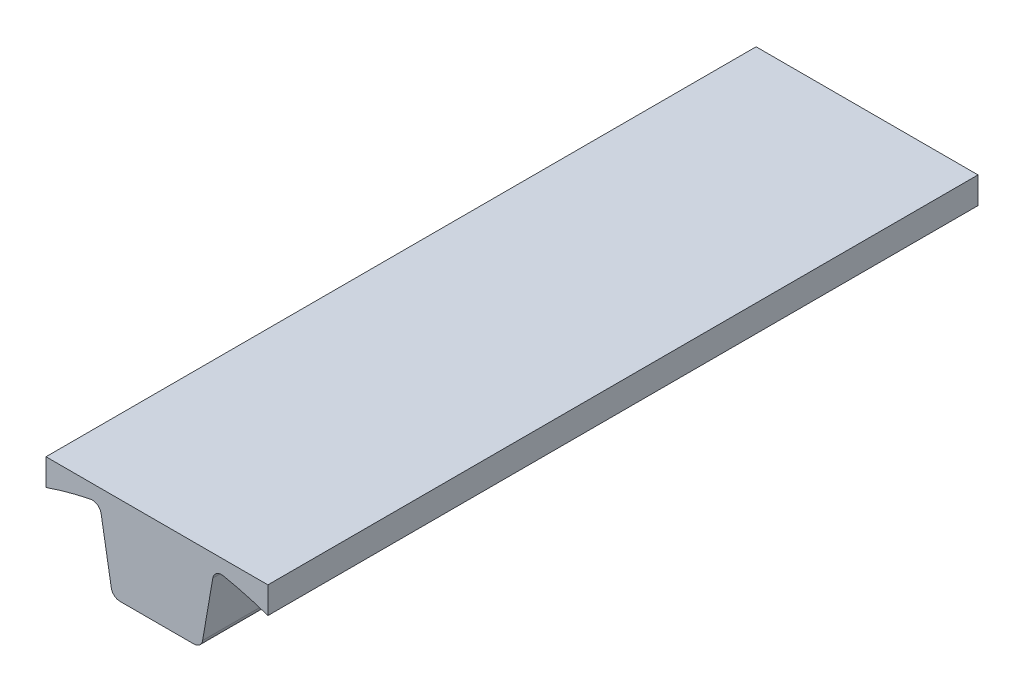
from build123d import *

# Parameters (mm, degrees)
BOSS_EXTRUDE1_DEPTH = 203.2
FILLET1_R           = 2.54
FILLET2_R           = 2.54
FILLET3_R           = 2.54
SKETCH2_R           = 2.667
CUT_EXTRUDE1_DEPTH  = 11.43


with BuildPart() as part:
    # Sketch1 → Boss-Extrude1 (new body)
    with BuildSketch(Plane.XY):
        with BuildLine():
            Line((-12.7, 73.846320133), (12.7, 73.846320133))
            Line((12.7, 73.846320133), (16.413720047, 95.436320133))
            ThreePointArc((16.413720047, 95.436320133), (24.162779869, 93.77452466), (31.75, 91.484637542))
            Line((31.75, 91.484637542), (31.75, 99.104637542))
            Line((31.75, 99.104637542), (-31.75, 99.104637542))
            Line((-31.75, 99.104637542), (-31.75, 91.484637542))
            ThreePointArc((-31.75, 91.484637542), (-24.162779869, 93.77452466), (-16.413720047, 95.436320133))
            Line((-16.413720047, 95.436320133), (-12.7, 73.846320133))
        make_face()
    extrude(amount=BOSS_EXTRUDE1_DEPTH)

    # Fillet1
    fillet1_edges = [part.edges().sort_by_distance(p)[0] for p in [
        (16.413720047, 95.436320133, 101.6),
    ]]
    fillet(fillet1_edges, radius=FILLET1_R)

    # Fillet2
    fillet2_edges = [part.edges().sort_by_distance(p)[0] for p in [
        (-16.413720047, 95.436320133, 101.6),
    ]]
    fillet(fillet2_edges, radius=FILLET2_R)

    # Fillet3
    fillet3_edges = [part.edges().sort_by_distance(p)[0] for p in [
        (12.7, 73.846320133, 101.6),
        (-12.7, 73.846320133, 101.6),
    ]]
    fillet(fillet3_edges, radius=FILLET3_R)

    # Sketch2 → Cut-Extrude1 (cut)
    with BuildSketch(Plane(origin=(0, 0, 0), x_dir=(-1, 0, 0), z_dir=(0, 0, -1))):
        with Locations((-8.89, 92.754637542)):
            Circle(SKETCH2_R)
        with Locations((8.89, 92.754637542)):
            Circle(SKETCH2_R)
        with Locations((0, 80.054637542)):
            Circle(SKETCH2_R)
    extrude(amount=-CUT_EXTRUDE1_DEPTH, mode=Mode.SUBTRACT)


solid = part.part
